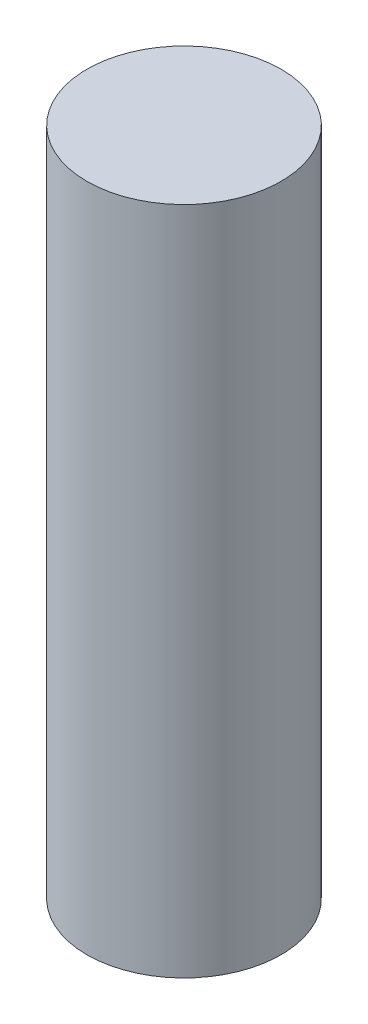
from build123d import *

# Parameters (mm, degrees)
SKETCH1_R           = 3.683
BOSS_EXTRUDE1_DEPTH = 25.4


with BuildPart() as part:
    # Sketch1 → Boss-Extrude1 (new body)
    with BuildSketch(Plane(origin=(0, 0, 0), x_dir=(1, 0, 0), z_dir=(0, 1, 0))):
        with Locations((2.999816581, -2.843818298)):
            Circle(SKETCH1_R)
    extrude(amount=BOSS_EXTRUDE1_DEPTH)


solid = part.part
